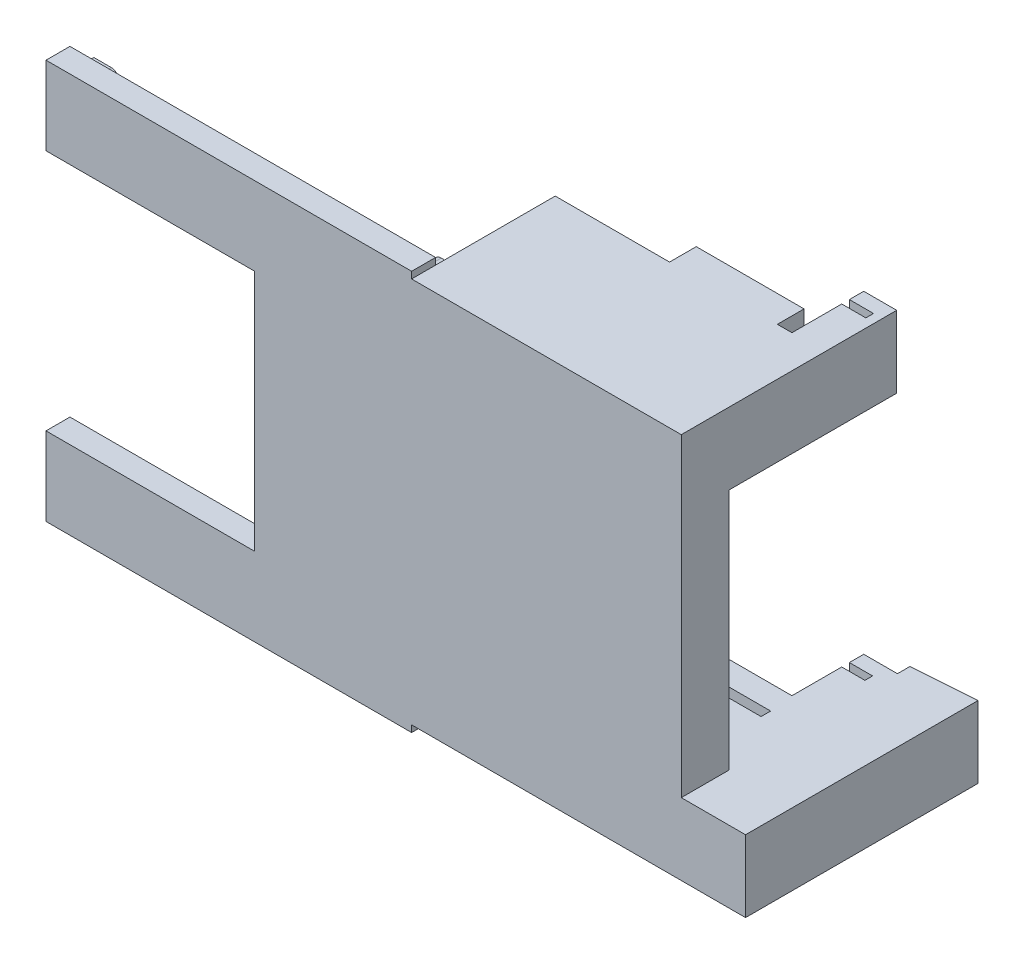
from build123d import *

# Parameters (mm, degrees)
SKETCH2_W               = 113.195063652
SKETCH2_H               = 64.34953214
BOSS_EXTRUDE1_DEPTH     = 6.35
SKETCH6_W               = 71.546023985
SKETCH6_H               = 19.05
BOSS_EXTRUDE4_DEPTH     = 38.1
SKETCH8_W               = 2.54
SKETCH8_H               = 16.51
CUT_EXTRUDE1_DEPTH      = 63.5
SKETCH11_W              = 97
SKETCH11_H              = 20.82
BOSS_EXTRUDE8_DEPTH     = 6.35
BOSS_EXTRUDE13_DEPTH    = 6.35
BOSS_EXTRUDE14_DEPTH    = 6.35
BOSS_EXTRUDE15_DEPTH    = 6.35
BOSS_EXTRUDE16_DEPTH    = 6.35
SKETCH20_W              = 17.045853961
SKETCH20_H              = 19.05
BOSS_EXTRUDE17_DEPTH    = 38.1
BOSS_EXTRUDE18_REACH    = 134.649
BOSS_EXTRUDE19_DEPTH    = 13.8
SKETCH23_W              = 17.153547373
SKETCH23_H              = 19.05
SKETCH23_W_2            = 8.74383249
SKETCH23_W_3            = 9.06979052
BOSS_EXTRUDE20_DEPTH    = 19.05
SKETCH24_W              = 8.538975884
SKETCH24_H              = 2.032
SKETCH24_W_2            = 6.156345993
CUT_EXTRUDE2_DEPTH      = 15.748
SKETCH25_W              = 6.404810212
SKETCH25_H              = 2.032
CUT_EXTRUDE3_DEPTH      = 153.153507472
SKETCH26_W              = 28.603496075
SKETCH26_H              = 19.05
BOSS_EXTRUDE21_DEPTH    = 7.085056153
BOSS_EXTRUDE22_DEPTH    = 6.35
SKETCH30_W              = 2.54
SKETCH30_H              = 54.505544918
CUT_EXTRUDE4_DEPTH      = 77.978
CUT_EXTRUDE4_DEPTH_BACK = 2.905744
SKETCH32_W              = 7.257489736
SKETCH32_H              = 15.118119189
CUT_EXTRUDE5_DEPTH      = 21.59


with BuildPart() as part:
    # Sketch2 → Boss-Extrude1 (new body)
    with BuildSketch(Plane.XY):
        with Locations((-1.348571368, 4.519536632)):
            Rectangle(SKETCH2_W, SKETCH2_H)
    extrude(amount=BOSS_EXTRUDE1_DEPTH)

    # Sketch6 → Boss-Extrude4 (add)
    with BuildSketch(Plane.XY.offset(6.35)):
        with Locations((19.475948466, 46.219302702)):
            Rectangle(SKETCH6_W, SKETCH6_H)
        with Locations((19.475948466, -37.180229438)):
            Rectangle(SKETCH6_W, SKETCH6_H)
    extrude(amount=-BOSS_EXTRUDE4_DEPTH)

    # Sketch8 → Cut-Extrude1 (cut)
    with BuildSketch(Plane.ZY.offset(16.297063527)):
        with Locations((-24.13, 44.949302702)):
            Rectangle(SKETCH8_W, SKETCH8_H)
        with Locations((-24.13, -35.910229438)):
            Rectangle(SKETCH8_W, SKETCH8_H)
    extrude(amount=-CUT_EXTRUDE1_DEPTH, mode=Mode.SUBTRACT)

    # Sketch11 → Boss-Extrude8 (add)
    with BuildSketch(Plane.XY.offset(6.35)):
        with Locations((-64.797063527, 47.104302702)):
            Rectangle(SKETCH11_W, SKETCH11_H)
        with Locations((-64.797063527, -38.065229438)):
            Rectangle(SKETCH11_W, SKETCH11_H)
    extrude(amount=-BOSS_EXTRUDE8_DEPTH)

    # Sketch16 → Boss-Extrude13 (add)
    with BuildSketch(Plane(origin=(0, 0, 0), x_dir=(-1, 0, 0), z_dir=(0, 0, -1))):
        with BuildLine():
            Line((16.297063527, 51.782302702), (21.12307027, 51.782302702))
            ThreePointArc((21.12307027, 51.782302702), (23.15507027, 49.75029933), (21.123063527, 47.718302702))
            Line((21.123063527, 47.718302702), (16.297063527, 47.718302702))
            Line((16.297063527, 47.718302702), (16.297063527, 51.782302702))
        make_face()
    extrude(amount=BOSS_EXTRUDE13_DEPTH)

    # Sketch17 → Boss-Extrude14 (add)
    with BuildSketch(Plane(origin=(0, 0, 0), x_dir=(-1, 0, 0), z_dir=(0, 0, -1))):
        with BuildLine():
            Line((16.297063527, -38.607229438), (21.12307027, -38.607229438))
            ThreePointArc((21.12307027, -38.607229438), (23.15507027, -40.63923281), (21.123063527, -42.671229438))
            Line((21.123063527, -42.671229438), (16.297063527, -42.671229438))
            Line((16.297063527, -42.671229438), (16.297063527, -38.607229438))
        make_face()
    extrude(amount=BOSS_EXTRUDE14_DEPTH)

    # Sketch18 → Boss-Extrude15 (add)
    with BuildSketch(Plane(origin=(0, 0, 0), x_dir=(-1, 0, 0), z_dir=(0, 0, -1))):
        with BuildLine():
            Line((113.297063527, 51.782302702), (108.696564152, 51.782302702))
            ThreePointArc((108.696564152, 51.782302702), (106.664564152, 49.750302702), (108.696564152, 47.718302702))
            Line((108.696564152, 47.718302702), (113.297063527, 47.718302702))
            Line((113.297063527, 47.718302702), (113.297063527, 51.782302702))
        make_face()
    extrude(amount=BOSS_EXTRUDE15_DEPTH)

    # Sketch19 → Boss-Extrude16 (add)
    with BuildSketch(Plane(origin=(0, 0, 0), x_dir=(-1, 0, 0), z_dir=(0, 0, -1))):
        with BuildLine():
            Line((113.297063527, -38.607229438), (108.696564152, -38.607229438))
            ThreePointArc((108.696564152, -38.607229438), (106.664564152, -40.639229438), (108.696564152, -42.671229438))
            Line((108.696564152, -42.671229438), (113.297063527, -42.671229438))
            Line((113.297063527, -42.671229438), (113.297063527, -38.607229438))
        make_face()
    extrude(amount=BOSS_EXTRUDE16_DEPTH)

    # Sketch20 → Boss-Extrude17 (add)
    with BuildSketch(Plane(origin=(0, 0, -31.75), x_dir=(-1, 0, 0), z_dir=(0, 0, -1))):
        with Locations((-63.771887439, -37.180229438)):
            Rectangle(SKETCH20_W, SKETCH20_H)
    extrude(amount=-BOSS_EXTRUDE17_DEPTH)

    # Boss-Extrude18: up to this plane
    boss_extrude18_end = Plane(origin=(55.616772372, -37.189415156, -54.156592283), z_dir=(-0.06975647374413249, 0, -0.9975640502598238))
    # Sketch21 → Boss-Extrude18 (add, up to the surface)
    with BuildSketch(Plane(origin=(0, 0, -31.75), x_dir=(-1, 0, 0), z_dir=(0, 0, -1)), mode=Mode.PRIVATE) as boss_extrude18_sk1:
        Polygon((-55.445234397, -27.655229438), (-55.574918488, -30.289415156), (-67.745199901, -30.289415156), (-67.745199901, -44.089415156), (-55.574918488, -44.089415156), (-55.574918488, -46.705229438), (-72.294814419, -46.705229438), (-72.294814419, -27.655229438), align=None)
    boss_extrude18_tool1 = split(extrude(boss_extrude18_sk1.sketch, amount=BOSS_EXTRUDE18_REACH, mode=Mode.PRIVATE), bisect_by=boss_extrude18_end, keep=Keep.BOTH, mode=Mode.PRIVATE)
    add(boss_extrude18_tool1.solids().sort_by_distance((55.764094, -28.959817, -31.75))[0])

    # Sketch22 → Boss-Extrude19 (add)
    with BuildSketch(Plane.XZ.offset(30.289415156)):
        Polygon((55.574918488, -47.316538406), (56.82562534, -47.316538406), (56.82562534, -54.153665574), (56.819539444, -54.24069795), (55.574918488, -54.153665574), align=None)
    extrude(amount=BOSS_EXTRUDE19_DEPTH)

    # Sketch23 → Boss-Extrude20 (add)
    with BuildSketch(Plane(origin=(0, 0, -31.75), x_dir=(-1, 0, 0), z_dir=(0, 0, -1))):
        with Locations((7.720289841, -37.180229438)):
            Rectangle(SKETCH23_W, SKETCH23_H)
        with Locations((-50.877044213, 46.219302702)):
            Rectangle(SKETCH23_W_2, SKETCH23_H)
        with Locations((-51.040023228, -37.180229438)):
            Rectangle(SKETCH23_W_3, SKETCH23_H)
    extrude(amount=BOSS_EXTRUDE20_DEPTH)

    # Sketch24 → Cut-Extrude2 (cut)
    with BuildSketch(Plane(origin=(0, -27.655229438, 0), x_dir=(1, 0, 0), z_dir=(0, 1, 0))):
        with Locations((-3.413004096, 45.974)):
            Rectangle(SKETCH24_W, SKETCH24_H)
        with Locations((49.583300965, 45.974)):
            Rectangle(SKETCH24_W_2, SKETCH24_H)
    extrude(amount=-CUT_EXTRUDE2_DEPTH, mode=Mode.SUBTRACT)

    # Sketch25 → Cut-Extrude3 (cut, through all)
    with BuildSketch(Plane.XZ.offset(-36.694302702)):
        with Locations((49.707533074, -45.974)):
            Rectangle(SKETCH25_W, SKETCH25_H)
    extrude(amount=-CUT_EXTRUDE3_DEPTH, mode=Mode.SUBTRACT)

    # Sketch26 → Boss-Extrude21 (add)
    with BuildSketch(Plane(origin=(0, 0, -31.75), x_dir=(-1, 0, 0), z_dir=(0, 0, -1))):
        with Locations((-28.33506354, 46.219302702)):
            Rectangle(SKETCH26_W, SKETCH26_H)
    extrude(amount=BOSS_EXTRUDE21_DEPTH)

    # Sketch27 → Boss-Extrude22 (add)
    with BuildSketch(Plane(origin=(0, 0, 0), x_dir=(-1, 0, 0), z_dir=(0, 0, -1))):
        Polygon((-55.248960458, 36.694302702), (-47.14593274, 36.694302702), (-47.14593274, 36.56022062), (27.224261785, 36.56022062), (27.224261785, 29.827699057), (-47.14593274, 29.827699057), (-47.14593274, -22.106759253), (30.255968743, -22.106759253), (30.255968743, -27.655229438), (-47.14593274, -27.655229438), (-55.248960458, -27.655229438), align=None)
    extrude(amount=BOSS_EXTRUDE22_DEPTH)

    # Sketch30 → Cut-Extrude4 (cut, two sides)
    with BuildSketch(Plane.ZY.offset(-47.14593274)) as cut_extrude4_sk:
        with Locations((-3.17615729, 3.825374341)):
            Rectangle(SKETCH30_W, SKETCH30_H)
    extrude(amount=CUT_EXTRUDE4_DEPTH, mode=Mode.SUBTRACT)
    extrude(cut_extrude4_sk.sketch, amount=-CUT_EXTRUDE4_DEPTH_BACK, mode=Mode.SUBTRACT)

    # Sketch32 → Cut-Extrude5 (cut)
    with BuildSketch(Plane.ZY.offset(-46.505127968)):
        with Locations((-35.378744868, -37.488489942)):
            Rectangle(SKETCH32_W, SKETCH32_H)
    extrude(amount=-CUT_EXTRUDE5_DEPTH, mode=Mode.SUBTRACT)


solid = part.part
